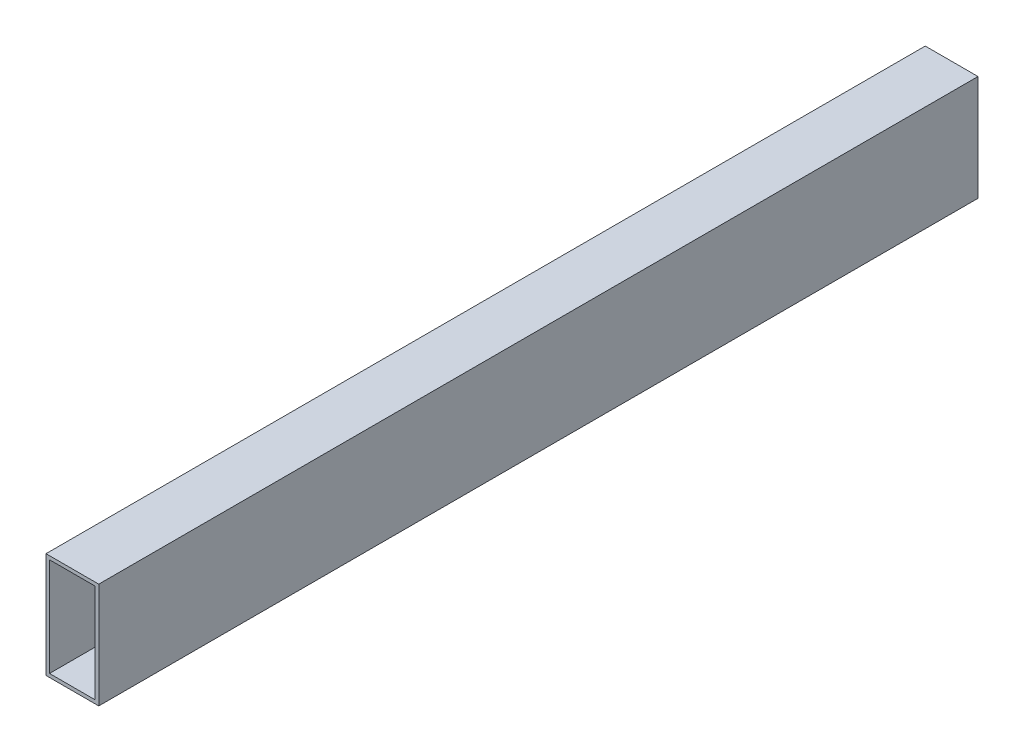
from build123d import *

# Parameters (mm, degrees)
SKETCH1_W   = 60
SKETCH1_H   = 120
SKETCH1_W_2 = 52
SKETCH1_H_2 = 112


with BuildPart() as part:
    # Sweep1: sweep along a curve in space
    with BuildLine() as sweep1_path:
        add(Edge.make_bspline(
            [(0, 0, -500), (0, 0, 500)],
            knots=[0, 0, 1, 1], degree=1))
    # Sketch1 → Sweep1 (sweep)
    with BuildSketch(Plane.XY):
        Rectangle(SKETCH1_W, SKETCH1_H)
        Rectangle(SKETCH1_W_2, SKETCH1_H_2, mode=Mode.SUBTRACT)
    sweep(path=sweep1_path.line)


solid = part.part
